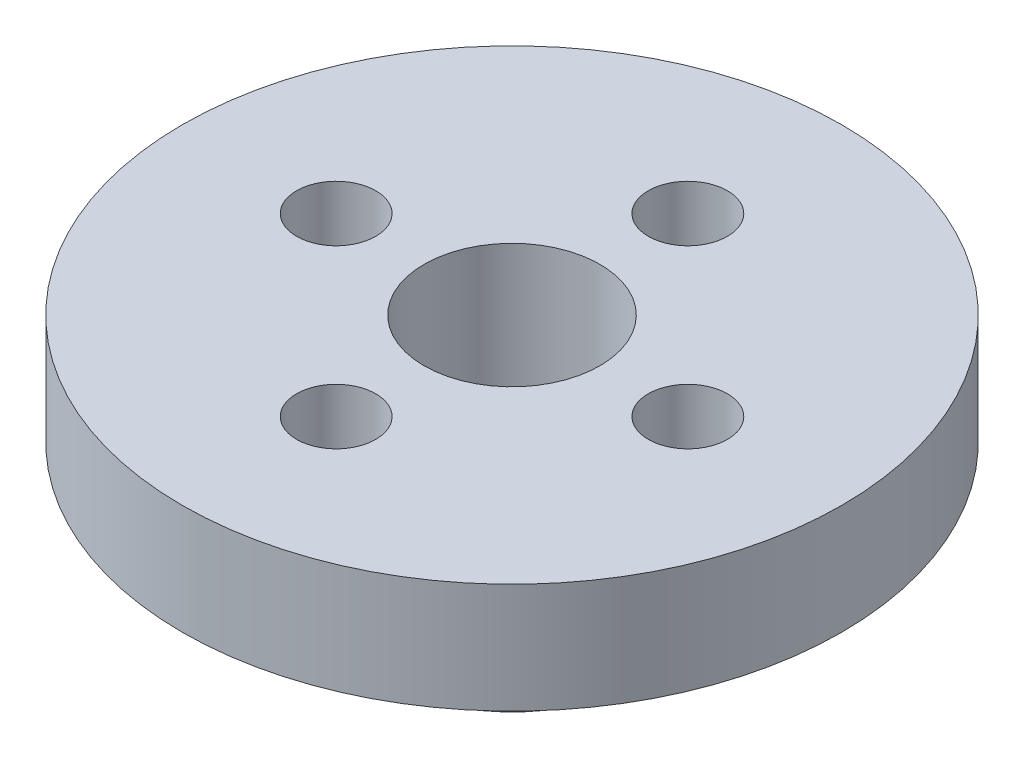
from build123d import *

# Parameters (mm, degrees)
SKETCH1_R           = 9.525
BOSS_EXTRUDE1_DEPTH = 3.175
SKETCH2_R           = 3.81
SKETCH2_R_2         = 2.54
BOSS_EXTRUDE2_DEPTH = 4.064
SKETCH3_R           = 2.54
SKETCH3_R_2         = 1.143
CUT_EXTRUDE1_DEPTH  = 3.175


with BuildPart() as part:
    # Sketch1 → Boss-Extrude1 (new body)
    with BuildSketch(Plane(origin=(0, 0, 0), x_dir=(1, 0, 0), z_dir=(0, 1, 0))):
        Circle(SKETCH1_R)
    extrude(amount=BOSS_EXTRUDE1_DEPTH)

    # Sketch2 → Boss-Extrude2 (add)
    with BuildSketch(Plane(origin=(0, 0, 0), x_dir=(1, 0, 0), z_dir=(0, 1, 0))):
        Circle(SKETCH2_R)
        Circle(SKETCH2_R_2, mode=Mode.SUBTRACT)
    extrude(amount=-BOSS_EXTRUDE2_DEPTH)

    # Sketch3 → Cut-Extrude1 (cut)
    with BuildSketch(Plane(origin=(0, 0, 0), x_dir=(1, 0, 0), z_dir=(0, 1, 0))):
        Circle(SKETCH3_R)
        with Locations((5.08, 0)):
            Circle(SKETCH3_R_2)
        with Locations((0, 5.08)):
            Circle(SKETCH3_R_2)
        with Locations((-5.08, 0)):
            Circle(SKETCH3_R_2)
        with Locations((0, -5.08)):
            Circle(SKETCH3_R_2)
    extrude(amount=CUT_EXTRUDE1_DEPTH, mode=Mode.SUBTRACT)


solid = part.part
